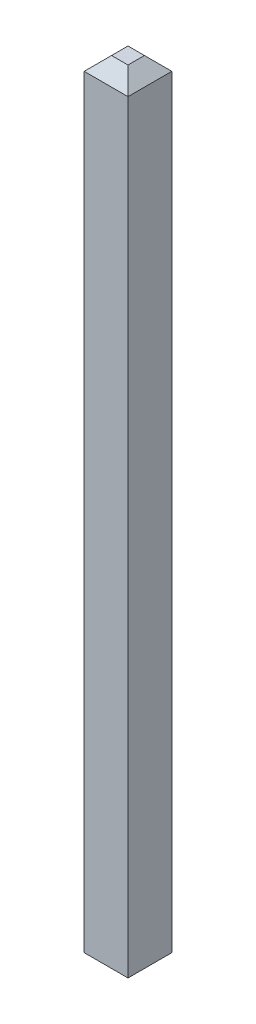
from build123d import *

# Parameters (mm, degrees)
SKETCH1_W           = 0.64
SKETCH1_H           = 0.64
BOSS_EXTRUDE1_DEPTH = 11.54
CHAMFER1_SIZE       = 0.2


with BuildPart() as part:
    # Sketch1 → Boss-Extrude1 (new body)
    with BuildSketch(Plane(origin=(0, 0, 0), x_dir=(1, 0, 0), z_dir=(0, 1, 0))):
        Rectangle(SKETCH1_W, SKETCH1_H)
    extrude(amount=BOSS_EXTRUDE1_DEPTH)

    # Chamfer1
    chamfer1_edges = [part.edges().sort_by_distance(p)[0] for p in [
        (0.32, 11.54, 0),
        (0, 11.54, -0.32),
        (-0.32, 11.54, 0),
        (0, 0, -0.32),
        (0.32, 0, 0),
        (0, 0, 0.32),
        (-0.32, 0, 0),
        (0, 11.54, 0.32),
    ]]
    chamfer(chamfer1_edges, length=CHAMFER1_SIZE)


solid = part.part
